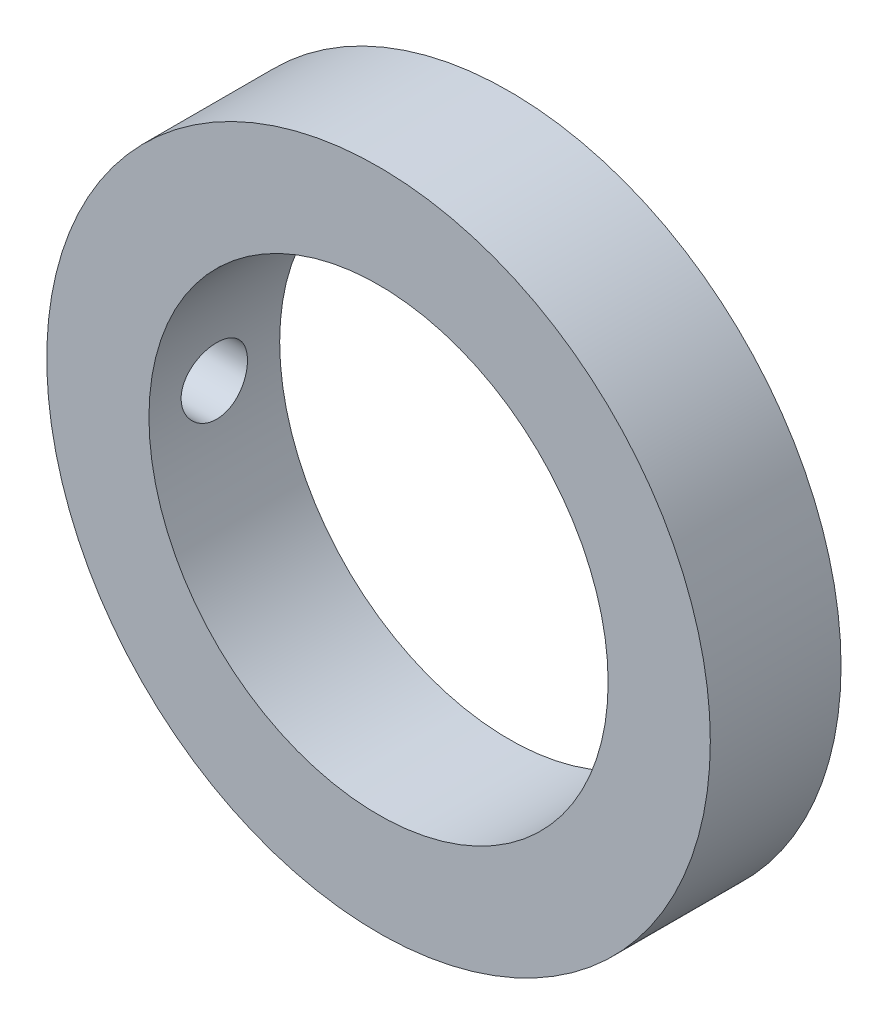
from build123d import *

# Parameters (mm, degrees)
ESBO_O1_R                = 25
ESBO_O1_R_2              = 17.3
RESSALTO_EXTRUS_O1_DEPTH = 9.85
ESBO_O2_R                = 2.5
CORTE_EXTRUS_O1_DEPTH    = 26


with BuildPart() as part:
    # Esboço1 → Ressalto-extrusão1 (new body)
    with BuildSketch(Plane.XY):
        Circle(ESBO_O1_R)
        Circle(ESBO_O1_R_2, mode=Mode.SUBTRACT)
    extrude(amount=RESSALTO_EXTRUS_O1_DEPTH)

    # Esboço2 → Corte-extrusão1 (cut, through all)
    with BuildSketch(Plane(origin=(0, 0, 0), x_dir=(0, 0, -1), z_dir=(1, 0, 0))):
        with Locations((-4.925, 0)):
            Circle(ESBO_O2_R)
    extrude(amount=-CORTE_EXTRUS_O1_DEPTH, mode=Mode.SUBTRACT)


solid = part.part
